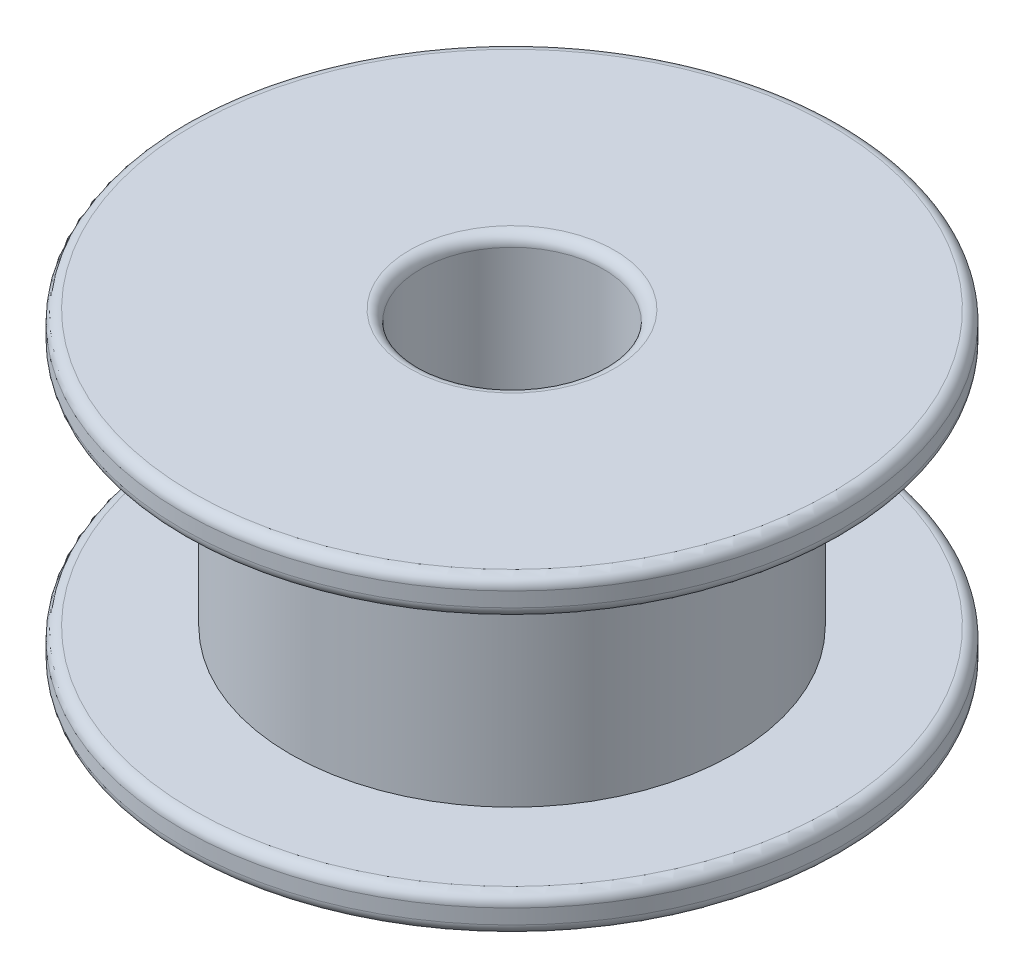
from build123d import *

# Parameters (mm, degrees)
SKETCH1_R           = 9
SKETCH1_R_2         = 2.5
BOSS_EXTRUDE1_DEPTH = 1
SKETCH2_R           = 6.05
SKETCH2_R_2         = 2.5
BOSS_EXTRUDE2_DEPTH = 6.5
SKETCH3_R           = 9
SKETCH3_R_2         = 2.5
BOSS_EXTRUDE3_DEPTH = 1
FILLET1_R           = 0.3


with BuildPart() as part:
    # Sketch1 → Boss-Extrude1 (new body)
    with BuildSketch(Plane(origin=(0, 0, 0), x_dir=(1, 0, 0), z_dir=(0, 1, 0))):
        Circle(SKETCH1_R)
        Circle(SKETCH1_R_2, mode=Mode.SUBTRACT)
    extrude(amount=BOSS_EXTRUDE1_DEPTH)

    # Sketch2 → Boss-Extrude2 (add)
    with BuildSketch(Plane(origin=(0, 1, 0), x_dir=(1, 0, 0), z_dir=(0, 1, 0))):
        Circle(SKETCH2_R)
        Circle(SKETCH2_R_2, mode=Mode.SUBTRACT)
    extrude(amount=BOSS_EXTRUDE2_DEPTH)

    # Sketch3 → Boss-Extrude3 (add)
    with BuildSketch(Plane(origin=(0, 7.5, 0), x_dir=(1, 0, 0), z_dir=(0, 1, 0))):
        Circle(SKETCH3_R)
        Circle(SKETCH3_R_2, mode=Mode.SUBTRACT)
    extrude(amount=BOSS_EXTRUDE3_DEPTH)

    # Fillet1
    fillet1_edges = [part.edges().sort_by_distance(p)[0] for p in [
        (-9, 8.5, 0),
        (-9, 7.5, 0),
        (-2.5, 8.5, 0),
        (-9, 0, 0),
        (-9, 1, 0),
        (-2.5, 0, 0),
    ]]
    fillet(fillet1_edges, radius=FILLET1_R)


solid = part.part
